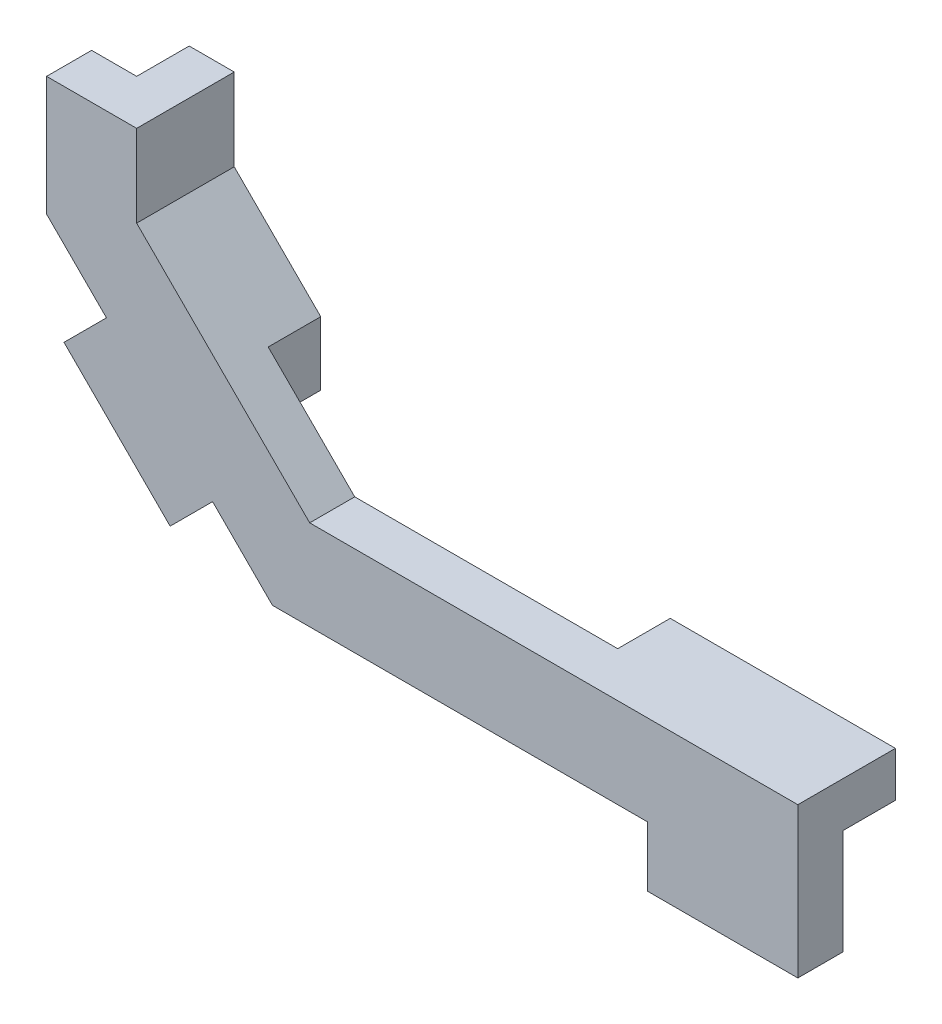
from build123d import *

# Parameters (mm, degrees)
SKETCH1_W           = 35
SKETCH1_H           = 3
BOSS_EXTRUDE1_DEPTH = 6
BOSS_EXTRUDE2_DEPTH = 3
SKETCH4_W           = 15
SKETCH4_H           = 3
BOSS_EXTRUDE3_DEPTH = 3.5
SKETCH5_W           = 10
SKETCH5_H           = 3
BOSS_EXTRUDE4_DEPTH = 4
SKETCH6_W           = 3
SKETCH6_H           = 10
BOSS_EXTRUDE5_DEPTH = 4


with BuildPart() as part:
    # Sketch1 → Boss-Extrude1 (new body)
    with BuildSketch(Plane(origin=(0, 0, 0), x_dir=(1, 0, 0), z_dir=(0, 1, 0))):
        Rectangle(SKETCH1_W, SKETCH1_H)
    extrude(amount=BOSS_EXTRUDE1_DEPTH)

    # Sketch3 → Boss-Extrude2 (add)
    with BuildSketch(Plane(origin=(0, 0, -1.5), x_dir=(-1, 0, 0), z_dir=(0, 0, -1))):
        Polygon((17.5, 0), (32.547232304, 15.047232304), (32.547232304, 22.997232304), (26.547232304, 22.997232304), (26.547232304, 17.527232304), (15.02, 6), (17.5, 6), align=None)
    extrude(amount=-BOSS_EXTRUDE2_DEPTH)

    # Sketch4 → Boss-Extrude3 (add)
    with BuildSketch(Plane(origin=(0, 0, -1.5), x_dir=(-1, 0, 0), z_dir=(0, 0, -1))):
        with Locations((-10, 4.5)):
            Rectangle(SKETCH4_W, SKETCH4_H)
        Polygon((20.783616152, 11.763616152), (26.547232304, 17.527232304), (26.547232304, 22.997232304), (29.547232304, 22.997232304), (29.547232304, 16.284591617), (20.783616152, 7.520975465), align=None)
    extrude(amount=BOSS_EXTRUDE3_DEPTH)

    # Sketch5 → Boss-Extrude4 (add)
    with BuildSketch(Plane.XZ):
        with Locations((12.5, 0)):
            Rectangle(SKETCH5_W, SKETCH5_H)
    extrude(amount=BOSS_EXTRUDE4_DEPTH)

    # Sketch6 → Boss-Extrude5 (add)
    with BuildSketch(Plane(origin=(-8.75, -8.75, 0), x_dir=(0, 0, 1), z_dir=(-0.707106781, -0.707106781, 0))):
        with Locations((0, 23.014368671)):
            Rectangle(SKETCH6_W, SKETCH6_H)
    extrude(amount=BOSS_EXTRUDE5_DEPTH)


solid = part.part
